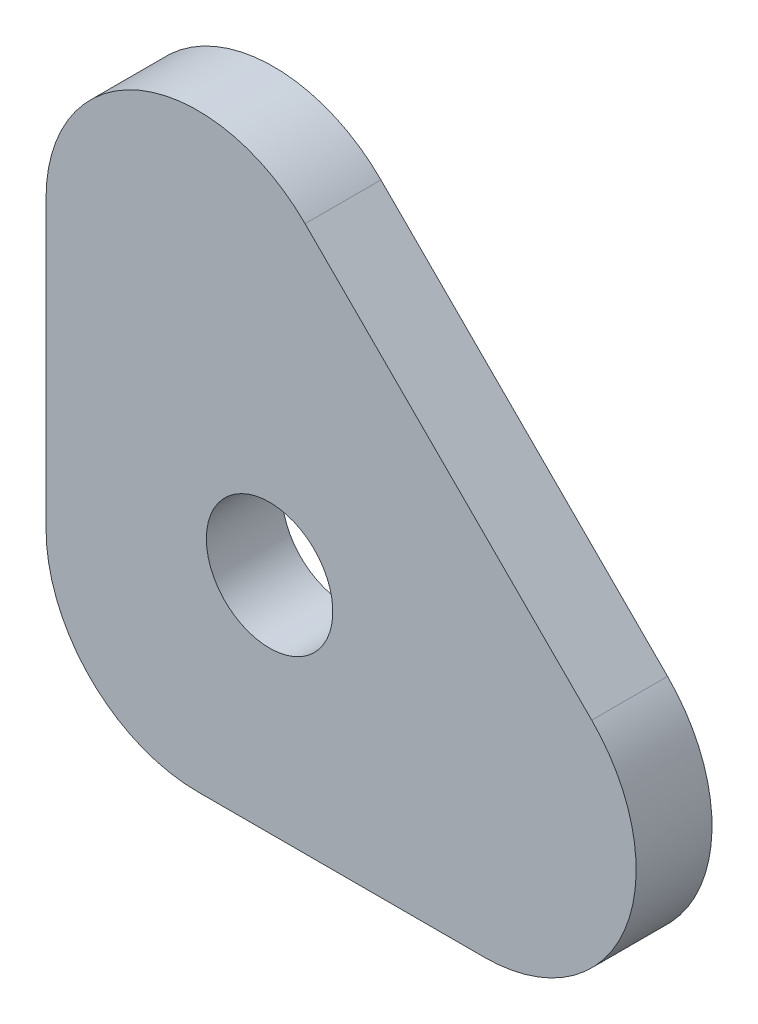
from build123d import *

# Parameters (mm, degrees)
BOSS_EXTRUDE1_START = -59
SKETCH1_R           = 5
BOSS_EXTRUDE1_DEPTH = 6


with BuildPart() as part:
    # Sketch1 → Boss-Extrude1 (new body)
    with BuildSketch(Plane.XY.offset(BOSS_EXTRUDE1_START)):
        with BuildLine():
            Line((-253.286796564, -275.955844123), (-275.955844123, -253.286796564))
            ThreePointArc((-275.955844123, -253.286796564), (-289.033326685, -250.685523549), (-296.441125497, -261.772077939))
            Line((-296.441125497, -261.772077939), (-296.441125497, -284.441125497))
            ThreePointArc((-296.441125497, -284.441125497), (-292.926406871, -292.926406871), (-284.441125497, -296.441125497))
            Line((-284.441125497, -296.441125497), (-261.772077939, -296.441125497))
            ThreePointArc((-261.772077939, -296.441125497), (-250.685523549, -289.033326685), (-253.286796564, -275.955844123))
        make_face()
        with Locations((-278.763455967, -278.763455967)):
            Circle(SKETCH1_R, mode=Mode.SUBTRACT)
    extrude(amount=BOSS_EXTRUDE1_DEPTH)


solid = part.part
